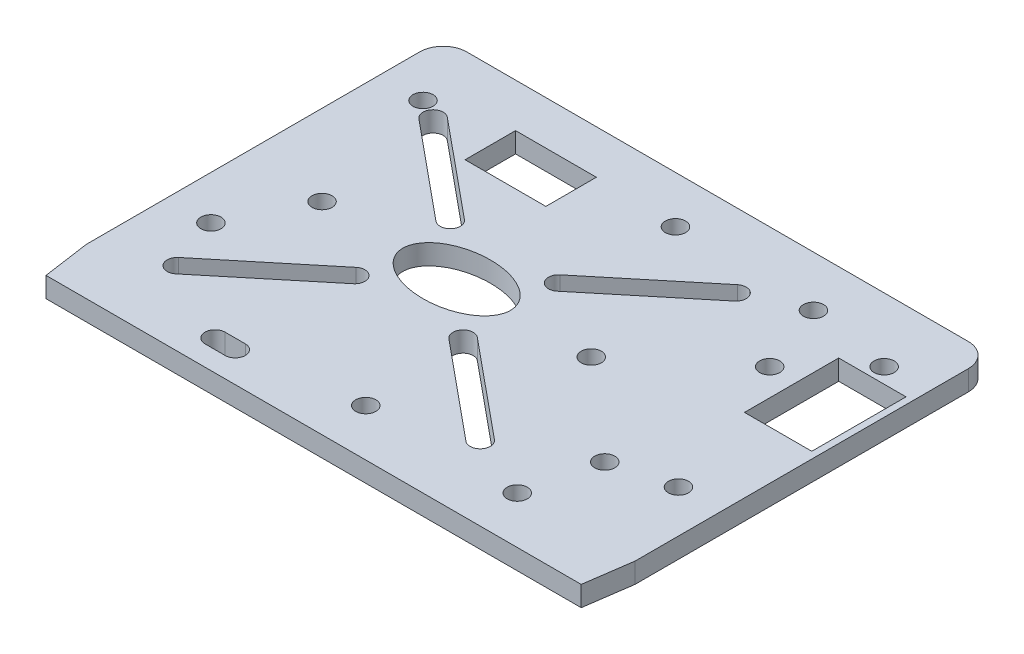
from build123d import *

# Parameters (mm, degrees)
CROQUIS1_R              = 1.5
CROQUIS1_RX             = 8
CROQUIS1_RY             = 5
CROQUIS1_W              = 10
CROQUIS1_H              = 14
CROQUIS1_W_2            = 12
CROQUIS1_H_2            = 7.5
SALIENTE_EXTRUIR1_DEPTH = 3


with BuildPart() as part:
    # Croquis1 → Saliente-Extruir1 (new body)
    with BuildSketch(Plane(origin=(0, 0, 0), x_dir=(1, 0, 0), z_dir=(0, 1, 0))):
        with BuildLine():
            Line((40.75, -26.5), (40.75, 23))
            ThreePointArc((40.75, 23), (39.724873734, 25.474873734), (37.25, 26.5))
            Line((37.25, 26.5), (-37.25, 26.5))
            ThreePointArc((-37.25, 26.5), (-39.724873734, 25.474873734), (-40.75, 23))
            Line((-40.75, 23), (-40.75, -26.5))
            Line((-40.75, -26.5), (-39.75, -33.5))
            Line((-39.75, -33.5), (39.75, -33.5))
            Line((39.75, -33.5), (40.75, -26.5))
        make_face()
        with Locations((34.25, 17)):
            Circle(CROQUIS1_R, mode=Mode.SUBTRACT)
        with Locations((-34.25, 17)):
            Circle(CROQUIS1_R, mode=Mode.SUBTRACT)
        with Locations((34.45, -13.75)):
            Circle(CROQUIS1_R, mode=Mode.SUBTRACT)
        with Locations((25.75, -16)):
            Circle(CROQUIS1_R, mode=Mode.SUBTRACT)
        with Locations((23.25, -26.5)):
            Circle(CROQUIS1_R, mode=Mode.SUBTRACT)
        with Locations((25.75, 8.5)):
            Circle(CROQUIS1_R, mode=Mode.SUBTRACT)
        with Locations((21.75, 19)):
            Circle(CROQUIS1_R, mode=Mode.SUBTRACT)
        with Locations((11.25, -3.5)):
            Circle(CROQUIS1_R, mode=Mode.SUBTRACT)
        with Locations((-28.75, -3.5)):
            Circle(CROQUIS1_R, mode=Mode.SUBTRACT)
        with Locations((0.75, -26.5)):
            Circle(CROQUIS1_R, mode=Mode.SUBTRACT)
        with Locations((0.75, 19.5)):
            Circle(CROQUIS1_R, mode=Mode.SUBTRACT)
        with Locations((-34.25, -14.5)):
            Circle(CROQUIS1_R, mode=Mode.SUBTRACT)
        with Locations((-8.75, -3.5)):
            Ellipse(CROQUIS1_RX, CROQUIS1_RY, mode=Mode.SUBTRACT)
        with Locations((34.75, 7.75)):
            Rectangle(CROQUIS1_W, CROQUIS1_H, mode=Mode.SUBTRACT)
        with BuildLine():
            Line((-1.658013335, 4.744885232), (12.795993333, 16.65752809))
            ThreePointArc((12.795993333, 16.65752809), (14.90752809, 16.454006667), (14.704006667, 14.34247191))
            Line((14.704006667, 14.34247191), (0.25, 2.429829053))
            ThreePointArc((0.25, 2.429829053), (-1.861534757, 2.633350475), (-1.658013335, 4.744885232))
        make_face(mode=Mode.SUBTRACT)
        with BuildLine():
            Line((-1.658013335, -11.744885232), (12.795993333, -23.65752809))
            ThreePointArc((12.795993333, -23.65752809), (14.90752809, -23.454006667), (14.704006667, -21.34247191))
            Line((14.704006667, -21.34247191), (0.25, -9.429829053))
            ThreePointArc((0.25, -9.429829053), (-1.861534757, -9.633350475), (-1.658013335, -11.744885232))
        make_face(mode=Mode.SUBTRACT)
        with BuildLine():
            Line((-15.841986665, -11.744885232), (-30.295993333, -23.65752809))
            ThreePointArc((-30.295993333, -23.65752809), (-32.40752809, -23.454006667), (-32.204006667, -21.34247191))
            Line((-32.204006667, -21.34247191), (-17.75, -9.429829053))
            ThreePointArc((-17.75, -9.429829053), (-15.638465243, -9.633350475), (-15.841986665, -11.744885232))
        make_face(mode=Mode.SUBTRACT)
        with BuildLine():
            Line((-15.841986665, 4.744885232), (-30.295993333, 16.65752809))
            ThreePointArc((-30.295993333, 16.65752809), (-32.40752809, 16.454006667), (-32.204006667, 14.34247191))
            Line((-32.204006667, 14.34247191), (-17.75, 2.429829053))
            ThreePointArc((-17.75, 2.429829053), (-15.638465243, 2.633350475), (-15.841986665, 4.744885232))
        make_face(mode=Mode.SUBTRACT)
        with BuildLine():
            Line((-19.142857143, -27.5), (-16.142857143, -27.5))
            ThreePointArc((-16.142857143, -27.5), (-14.642857143, -29), (-16.142857143, -30.5))
            Line((-16.142857143, -30.5), (-19.142857143, -30.5))
            ThreePointArc((-19.142857143, -30.5), (-20.642857143, -29), (-19.142857143, -27.5))
        make_face(mode=Mode.SUBTRACT)
        with Locations((-17.5, 16.25)):
            Rectangle(CROQUIS1_W_2, CROQUIS1_H_2, mode=Mode.SUBTRACT)
    extrude(amount=SALIENTE_EXTRUIR1_DEPTH)


solid = part.part
